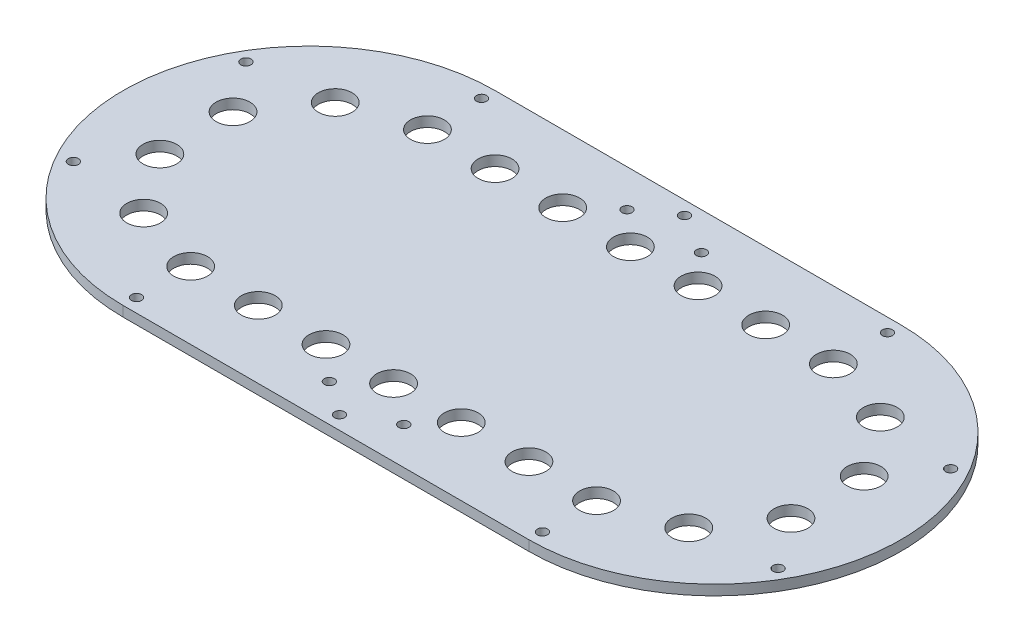
from build123d import *

# Parameters (mm, degrees)
SKETCH_1_R          = 1.5
EXTRUDE_2_DEPTH     = 3
CUT_EXTRUDE_1_DEPTH = 10
SKETCH_4_R          = 5
CUT_EXTRUDE_2_DEPTH = 10
SKETCH_5_R          = 1.5
CUT_EXTRUDE_3_DEPTH = 10
SKETCH_6_R          = 1.5
CUT_EXTRUDE_4_DEPTH = 10


with BuildPart() as part:
    # 草图1 → 凸台-拉伸2 (new body)
    with BuildSketch(Plane(origin=(0, 0, 0), x_dir=(1, 0, 0), z_dir=(0, 1, 0))):
        with BuildLine():
            Line((-60, 70), (60, 70))
            ThreePointArc((60, 70), (130, 0), (60, -70))
            Line((60, -70), (-60, -70))
            ThreePointArc((-60, -70), (-130, 0), (-60, 70))
        make_face()
        with Locations((-122, 0)):
            Circle(SKETCH_1_R, mode=Mode.SUBTRACT)
        with Locations((122, 0)):
            Circle(SKETCH_1_R, mode=Mode.SUBTRACT)
        with Locations((-30, 60)):
            Circle(SKETCH_1_R, mode=Mode.SUBTRACT)
        with Locations((30, 60)):
            Circle(SKETCH_1_R, mode=Mode.SUBTRACT)
        with Locations((30, -60)):
            Circle(SKETCH_1_R, mode=Mode.SUBTRACT)
        with Locations((-30, -60)):
            Circle(SKETCH_1_R, mode=Mode.SUBTRACT)
    extrude(amount=EXTRUDE_2_DEPTH)

    # 草图3 → 切除-拉伸1 (cut)
    with BuildSketch(Plane(origin=(0, 3, 0), x_dir=(1, 0, 0), z_dir=(0, 1, 0))):
        with BuildLine():
            Line((-60, -70), (60, -70))
            ThreePointArc((60, -70), (130, 0), (60, 70))
            Line((60, 70), (-60, 70))
            ThreePointArc((-60, 70), (-130, 0), (-60, -70))
        make_face()
        with BuildLine():
            Line((-60, -55), (60, -55))
            ThreePointArc((60, -55), (115, 0), (60, 55))
            Line((60, 55), (-60, 55))
            ThreePointArc((-60, 55), (-115, 0), (-60, -55))
        make_face(mode=Mode.SUBTRACT)
    extrude(amount=-CUT_EXTRUDE_1_DEPTH, mode=Mode.SUBTRACT)

    # 草图4 → 切除-拉伸2 (cut)
    with BuildSketch(Plane(origin=(0, 3, 0), x_dir=(1, 0, 0), z_dir=(0, 1, 0))):
        with Locations((-60, 35)):
            Circle(SKETCH_4_R)
        with Locations((-60, -35)):
            Circle(SKETCH_4_R)
        with Locations((-80.57248383, -28.315594803)):
            Circle(SKETCH_4_R)
        with Locations((-93.28697807, -10.815594803)):
            Circle(SKETCH_4_R)
        with Locations((-93.28697807, 10.815594803)):
            Circle(SKETCH_4_R)
        with Locations((-80.57248383, 28.315594803)):
            Circle(SKETCH_4_R)
        with Locations((-40, 35)):
            Circle(SKETCH_4_R)
        with Locations((-20, 35)):
            Circle(SKETCH_4_R)
        with Locations((0, 35)):
            Circle(SKETCH_4_R)
        with Locations((20, 35)):
            Circle(SKETCH_4_R)
        with Locations((40, 35)):
            Circle(SKETCH_4_R)
        with Locations((60, 35)):
            Circle(SKETCH_4_R)
        with Locations((60, -35)):
            Circle(SKETCH_4_R)
        with Locations((40, -35)):
            Circle(SKETCH_4_R)
        with Locations((20, -35)):
            Circle(SKETCH_4_R)
        with Locations((0, -35)):
            Circle(SKETCH_4_R)
        with Locations((-20, -35)):
            Circle(SKETCH_4_R)
        with Locations((-40, -35)):
            Circle(SKETCH_4_R)
        with Locations((80.57248383, 28.315594803)):
            Circle(SKETCH_4_R)
        with Locations((93.28697807, 10.815594803)):
            Circle(SKETCH_4_R)
        with Locations((93.28697807, -10.815594803)):
            Circle(SKETCH_4_R)
        with Locations((80.57248383, -28.315594803)):
            Circle(SKETCH_4_R)
    extrude(amount=-CUT_EXTRUDE_2_DEPTH, mode=Mode.SUBTRACT)

    # 草图5 → 切除-拉伸3 (cut)
    with BuildSketch(Plane(origin=(0, 3, 0), x_dir=(1, 0, 0), z_dir=(0, 1, 0))):
        with Locations((60, 51)):
            Circle(SKETCH_5_R)
        with Locations((104.167295593, 25.5)):
            Circle(SKETCH_5_R)
        with Locations((104.167295593, -25.5)):
            Circle(SKETCH_5_R)
        with Locations((60, -51)):
            Circle(SKETCH_5_R)
        with Locations((0, -51)):
            Circle(SKETCH_5_R)
        with Locations((-60, -51)):
            Circle(SKETCH_5_R)
        with Locations((-104.167295593, -25.5)):
            Circle(SKETCH_5_R)
        with Locations((-104.167295593, 25.5)):
            Circle(SKETCH_5_R)
        with Locations((-60, 51)):
            Circle(SKETCH_5_R)
        with Locations((0, 51)):
            Circle(SKETCH_5_R)
    extrude(amount=-CUT_EXTRUDE_3_DEPTH, mode=Mode.SUBTRACT)

    # 草图6 → 切除-拉伸4 (cut)
    with BuildSketch(Plane(origin=(0, 3, 0), x_dir=(1, 0, 0), z_dir=(0, 1, 0))):
        with Locations((-10, -44)):
            Circle(SKETCH_6_R)
        with Locations((-10, 44)):
            Circle(SKETCH_6_R)
        with Locations((12, -44)):
            Circle(SKETCH_6_R)
        with Locations((12, 44)):
            Circle(SKETCH_6_R)
    extrude(amount=-CUT_EXTRUDE_4_DEPTH, mode=Mode.SUBTRACT)


solid = part.part
